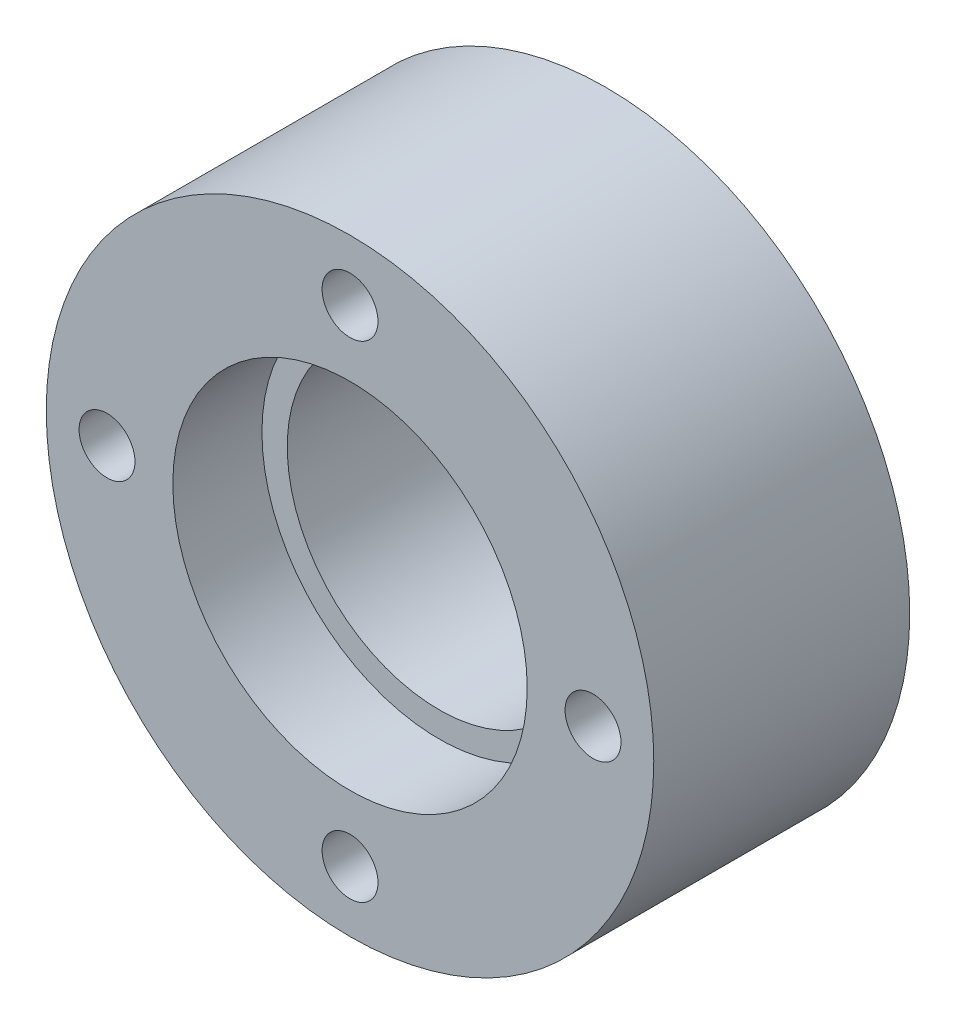
from build123d import *

# Parameters (mm, degrees)
SKETCH1_R           = 19.05
SKETCH1_R_2         = 9.525
SKETCH1_R_3         = 1.7526
BOSS_EXTRUDE1_DEPTH = 16.0528
SKETCH2_R           = 11.1125
CUT_EXTRUDE2_DEPTH  = 5.588


with BuildPart() as part:
    # Sketch1 → Boss-Extrude1 (new body)
    with BuildSketch(Plane.XY):
        Circle(SKETCH1_R)
        Circle(SKETCH1_R_2, mode=Mode.SUBTRACT)
        with Locations((0, 15.24)):
            Circle(SKETCH1_R_3, mode=Mode.SUBTRACT)
        with Locations((15.24, 0)):
            Circle(SKETCH1_R_3, mode=Mode.SUBTRACT)
        with Locations((0, -15.24)):
            Circle(SKETCH1_R_3, mode=Mode.SUBTRACT)
        with Locations((-15.24, 0)):
            Circle(SKETCH1_R_3, mode=Mode.SUBTRACT)
    extrude(amount=BOSS_EXTRUDE1_DEPTH)

    # Sketch2 → Cut-Extrude2 (cut)
    with BuildSketch(Plane.XY.offset(16.0528)):
        Circle(SKETCH2_R)
    extrude(amount=-CUT_EXTRUDE2_DEPTH, mode=Mode.SUBTRACT)


solid = part.part
